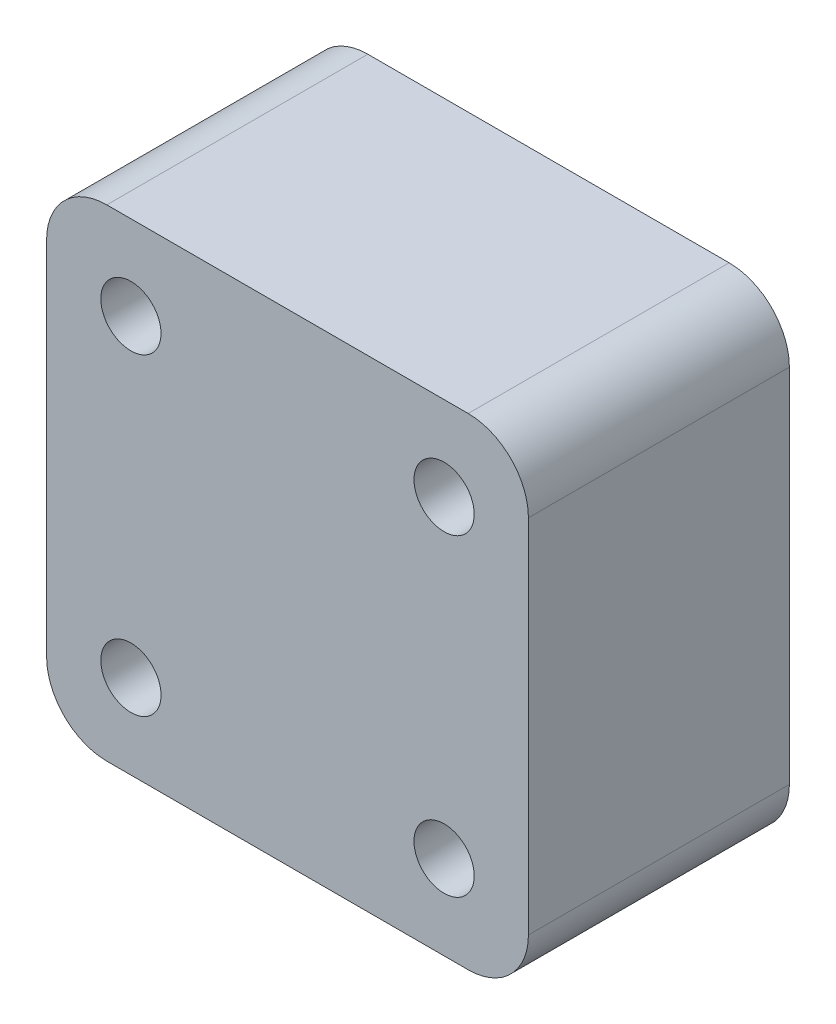
from build123d import *

# Parameters (mm, degrees)
ESBO_O1_W                = 48
ESBO_O1_H                = 48
RESSALTO_EXTRUS_O1_DEPTH = 26
ESBO_O3_R                = 3
CORTE_EXTRUS_O2_DEPTH    = 27
FILETE2_R                = 6


with BuildPart() as part:
    # Esboço1 → Ressalto-extrusão1 (new body)
    with BuildSketch(Plane.XY):
        Rectangle(ESBO_O1_W, ESBO_O1_H)
    extrude(amount=RESSALTO_EXTRUS_O1_DEPTH)

    # Esboço3 → Corte-extrusão2 (cut, through all)
    with BuildSketch(Plane.XY.offset(26)):
        with Locations((-15.6, -15.6)):
            Circle(ESBO_O3_R)
        with Locations((-15.6, 15.6)):
            Circle(ESBO_O3_R)
        with Locations((15.6, -15.6)):
            Circle(ESBO_O3_R)
        with Locations((15.6, 15.6)):
            Circle(ESBO_O3_R)
    extrude(amount=-CORTE_EXTRUS_O2_DEPTH, mode=Mode.SUBTRACT)

    # Filete2
    filete2_edges = [part.edges().sort_by_distance(p)[0] for p in [
        (24, -24, 13),
        (-24, -24, 13),
        (-24, 24, 13),
        (24, 24, 13),
    ]]
    fillet(filete2_edges, radius=FILETE2_R)


solid = part.part
